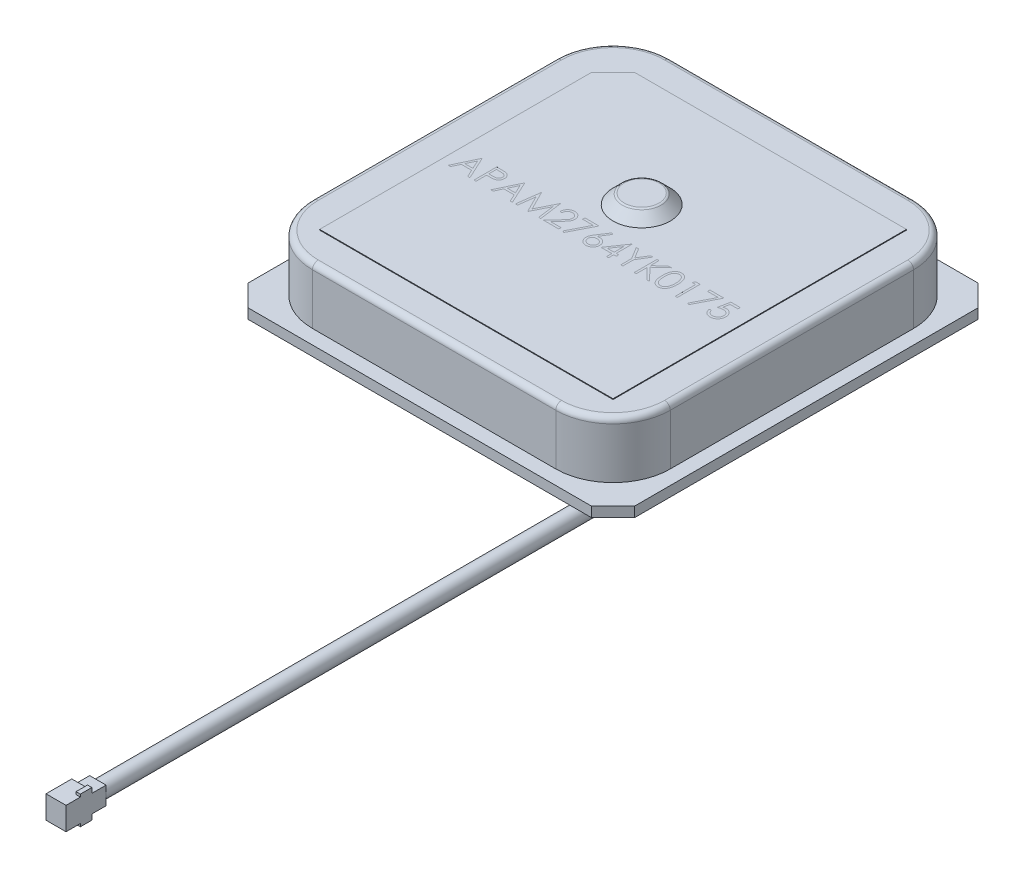
from build123d import *

# Parameters (mm, degrees)
SKETCH1_W                 = 27
SKETCH1_H                 = 27
BOSS_EXTRUDE1_DEPTH       = 0.7
CHAMFER2_SIZE             = 1.5
SKETCH2_W                 = 25
SKETCH2_H                 = 25
BOSS_EXTRUDE3_DEPTH       = 3.95
FILLET3_R                 = 4
FILLET4_R                 = 0.4
SKETCH5_W                 = 20.5
SKETCH5_H                 = 20.5
BOSS_EXTRUDE6_DEPTH       = 0.05
CHAMFER1_SIZE             = 1.5
SKETCH4_R                 = 2
BOSS_EXTRUDE5_DEPTH       = 0.7
BOSS_EXTRUDE5_TAPER       = 45
FILLET1_R                 = 0.2
SKETCH3_W                 = 15
SKETCH3_H                 = 11
BOSS_EXTRUDE4_DEPTH       = 1.3
SKETCH6_R                 = 0.565
BOSS_EXTRUDE10_DEPTH      = 48
SKETCH7_W                 = 1.8
SKETCH7_H                 = 1.6
BOSS_EXTRUDE11_DEPTH      = 1.4
SKETCH8_W                 = 1
SKETCH8_H                 = 1.25
BOSS_EXTRUDE12_DEPTH      = 1.15
SKETCH9_W                 = 0.3
SKETCH9_H                 = 0.8
BOSS_EXTRUDE13_DEPTH      = 0.18
BOSS_EXTRUDE13_DEPTH_BACK = 1.8
CUT_EXTRUDE1_DEPTH        = 0.0001


with BuildPart() as part:
    # Sketch1 → Boss-Extrude1 (new body)
    with BuildSketch(Plane(origin=(0, 0, 0), x_dir=(1, 0, 0), z_dir=(0, 1, 0))):
        Rectangle(SKETCH1_W, SKETCH1_H)
    extrude(amount=BOSS_EXTRUDE1_DEPTH)

    # Chamfer2
    chamfer2_edges = [part.edges().sort_by_distance(p)[0] for p in [
        (-13.5, 0.35, -13.5),
        (13.5, 0.35, -13.5),
        (13.5, 0.35, 13.5),
        (-13.5, 0.35, 13.5),
    ]]
    chamfer(chamfer2_edges, length=CHAMFER2_SIZE)

    # Sketch3 → Boss-Extrude4 (add)
    with BuildSketch(Plane(origin=(0, 0, 0), x_dir=(-1, 0, 0), z_dir=(0, -1, 0))):
        with Locations((-4, 4)):
            Rectangle(SKETCH3_W, SKETCH3_H)
    extrude(amount=BOSS_EXTRUDE4_DEPTH)


with BuildPart() as body_2:
    # Sketch2 → Boss-Extrude3 (new body)
    with BuildSketch(Plane(origin=(0, 0.7, 0), x_dir=(1, 0, 0), z_dir=(0, 1, 0))):
        Rectangle(SKETCH2_W, SKETCH2_H)
    extrude(amount=BOSS_EXTRUDE3_DEPTH)

    # Fillet3
    fillet3_edges = [body_2.edges().sort_by_distance(p)[0] for p in [
        (-12.5, 2.675, -12.5),
        (12.5, 2.675, -12.5),
        (12.5, 2.675, 12.5),
        (-12.5, 2.675, 12.5),
    ]]
    fillet(fillet3_edges, radius=FILLET3_R)

    # Fillet4
    fillet4_edges = [body_2.edges().sort_by_distance(p)[0] for p in [
        (0, 4.65, -12.5),
        (12.5, 4.65, 0),
        (-12.5, 4.65, 0),
        (0, 4.65, 12.5),
        (-11.328427125, 4.65, -11.328427125),
        (-11.328427125, 4.65, 11.328427125),
        (11.328427125, 4.65, 11.328427125),
        (11.328427125, 4.65, -11.328427125),
    ]]
    fillet(fillet4_edges, radius=FILLET4_R)

    # Sketch5 → Boss-Extrude6 (add)
    with BuildSketch(Plane(origin=(0, 4.65, 0), x_dir=(1, 0, 0), z_dir=(0, 1, 0))):
        Rectangle(SKETCH5_W, SKETCH5_H)
    extrude(amount=BOSS_EXTRUDE6_DEPTH)

    # Chamfer1
    chamfer1_edges = [body_2.edges().sort_by_distance(p)[0] for p in [
        (-10.25, 4.675, -10.25),
    ]]
    chamfer(chamfer1_edges, length=CHAMFER1_SIZE)

    # Sketch4 → Boss-Extrude5 (add)
    with BuildSketch(Plane(origin=(0, 4.7, 0), x_dir=(1, 0, 0), z_dir=(0, 1, 0))):
        with Locations((-0.5, 2.5)):
            Circle(SKETCH4_R)
    extrude(amount=BOSS_EXTRUDE5_DEPTH, taper=BOSS_EXTRUDE5_TAPER)

    # Fillet1
    fillet1_edges = [body_2.edges().sort_by_distance(p)[0] for p in [
        (-1.8, 5.4, -2.5),
    ]]
    fillet(fillet1_edges, radius=FILLET1_R)

    # Sketch10 → Cut-Extrude1 (cut)
    with BuildSketch(Plane(origin=(0, 4.7, 0), x_dir=(1, 0, 0), z_dir=(0, 1, 0))):
        Polygon((-8.856166827, -0.288785041), (-8.123474519, -1.876285041), (-8.278344812, -1.876285041), (-8.513035317, -1.367470939), (-9.232689263, -1.367470939), (-9.474057953, -1.876285041), (-9.629564263, -1.876285041), (-8.876519391, -0.288785041), align=None)
        Polygon((-8.867933153, -0.598207617), (-9.155413121, -1.204650426), (-8.588085397, -1.204650426), align=None, mode=Mode.SUBTRACT)
        with BuildLine():
            Line((-7.838538622, -0.288785041), (-7.527207993, -0.288785041))
            add(Edge.make_bspline(
                [(-7.527207993, -0.288785041), (-7.505794475, -0.28880858), (-7.464765223, -0.288853681), (-7.40593018, -0.290221083), (-7.352495052, -0.292047476), (-7.304575057, -0.294579263), (-7.262022756, -0.297571288), (-7.225030695, -0.301767749), (-7.19330811, -0.306149383), (-7.174300542, -0.310604092), (-7.165631971, -0.312635702)],
                knots=[0, 0, 0, 0, 6.4239e-05, 0.000123084, 0.000176543, 0.00022463, 0.000267045, 0.000304481, 0.000336323, 0.000363021, 0.000363021, 0.000363021, 0.000363021], degree=3))
            add(Edge.make_bspline(
                [(-7.165631971, -0.312635702), (-7.154658476, -0.315639229), (-7.132970061, -0.32157551), (-7.101718516, -0.333465306), (-7.071985165, -0.347563288), (-7.043667994, -0.363630575), (-7.017114978, -0.382356527), (-6.991929952, -0.402982061), (-6.968335175, -0.425983379), (-6.94646333, -0.451102501), (-6.926377011, -0.477917739), (-6.909082476, -0.506829393), (-6.894601198, -0.537350806), (-6.882180928, -0.569460747), (-6.873241737, -0.603428858), (-6.866507607, -0.639019117), (-6.862233319, -0.676227708), (-6.861823943, -0.701654862), (-6.861615545, -0.714598843)],
                knots=[0, 0, 0, 0, 3.4116e-05, 6.7428e-05, 0.000100146, 0.000132766, 0.000164967, 0.0001975, 0.000230334, 0.00026369, 0.000297336, 0.000330713, 0.000364566, 0.000398585, 0.00043384, 0.000469765, 0.000507201, 0.000546019, 0.000546019, 0.000546019, 0.000546019], degree=3))
            add(Edge.make_bspline(
                [(-6.861615545, -0.714598843), (-6.861806691, -0.72765162), (-6.862180682, -0.753190261), (-6.866669354, -0.790552204), (-6.872715548, -0.826256617), (-6.882012425, -0.860224332), (-6.894188856, -0.892253628), (-6.908472751, -0.922833972), (-6.925700995, -0.951445109), (-6.945497043, -0.978190909), (-6.967518659, -1.003096476), (-6.99167267, -1.025981329), (-7.017861564, -1.046711512), (-7.046002109, -1.065333496), (-7.076368648, -1.081415451), (-7.108500625, -1.095819658), (-7.14267733, -1.107916889), (-7.166327685, -1.114280524), (-7.178352324, -1.117516011)],
                knots=[0, 0, 0, 0, 3.9136e-05, 7.6572e-05, 0.000112752, 0.0001477, 0.000182017, 0.000215446, 0.000248823, 0.000282024, 0.000315141, 0.000348434, 0.000381709, 0.000415226, 0.000449515, 0.000484677, 0.000520786, 0.000558134, 0.000558134, 0.000558134, 0.000558134], degree=3))
            add(Edge.make_bspline(
                [(-7.178352324, -1.117516011), (-7.188297936, -1.119631006), (-7.210094323, -1.12426614), (-7.245991201, -1.12944069), (-7.287785715, -1.133857388), (-7.335420821, -1.137168975), (-7.38885376, -1.140003964), (-7.448113437, -1.142257349), (-7.51331618, -1.143495533), (-7.558796351, -1.143559392), (-7.582541527, -1.143592733)],
                knots=[0, 0, 0, 0, 3.0497e-05, 6.6837e-05, 0.000108733, 0.000156563, 0.000210065, 0.000269256, 0.00033446, 0.000405695, 0.000405695, 0.000405695, 0.000405695], degree=3))
            Line((-7.582541527, -1.143592733), (-7.696070673, -1.143592733))
            Line((-7.696070673, -1.143592733), (-7.696070673, -1.876285041))
            Line((-7.696070673, -1.876285041), (-7.838538622, -1.876285041))
            Line((-7.838538622, -1.876285041), (-7.838538622, -0.288785041))
        make_face()
        with BuildLine():
            Line((-7.696070673, -0.451605554), (-7.696070673, -0.980772221))
            Line((-7.696070673, -0.980772221), (-7.41813097, -0.984270318))
            add(Edge.make_bspline(
                [(-7.41813097, -0.984270318), (-7.404560146, -0.984277331), (-7.378361951, -0.984290871), (-7.340517664, -0.982483288), (-7.305407023, -0.980396618), (-7.273137877, -0.977341395), (-7.243695678, -0.973022825), (-7.217031334, -0.968663215), (-7.193351602, -0.96235614), (-7.16563875, -0.953863891), (-7.134758089, -0.939380169), (-7.101163165, -0.918357183), (-7.072692221, -0.891559862), (-7.048054993, -0.861430095), (-7.028503399, -0.827911562), (-7.014190502, -0.792048151), (-7.005780763, -0.754207662), (-7.004653096, -0.728314113), (-7.004083494, -0.715234861)],
                knots=[0, 0, 0, 0, 4.0706e-05, 7.8583e-05, 0.000113635, 0.000146227, 0.000175774, 0.00020291, 0.000227206, 0.000249231, 0.000289788, 0.00032913, 0.000367614, 0.000406503, 0.000445554, 0.000483525, 0.000521951, 0.00056117, 0.00056117, 0.00056117, 0.00056117], degree=3))
            add(Edge.make_bspline(
                [(-7.004083494, -0.715234861), (-7.004656194, -0.702472035), (-7.005794652, -0.677101117), (-7.014256418, -0.639917894), (-7.028475571, -0.604432413), (-7.048186241, -0.571333907), (-7.07210811, -0.541312556), (-7.099911741, -0.515233502), (-7.131531685, -0.494268659), (-7.160944989, -0.480737134), (-7.187071242, -0.472475206), (-7.209764309, -0.46669451), (-7.235386865, -0.462079146), (-7.263947251, -0.458341943), (-7.2952241, -0.455142695), (-7.329486122, -0.452971912), (-7.366603524, -0.451701252), (-7.392371176, -0.451638225), (-7.405728626, -0.451605554)],
                knots=[0, 0, 0, 0, 3.8268e-05, 7.6073e-05, 0.000113748, 0.000152526, 0.000191214, 0.000228567, 0.000266404, 0.00030454, 0.000325257, 0.00034855, 0.000374747, 0.000403306, 0.000434949, 0.000469048, 0.000506277, 0.000546348, 0.000546348, 0.000546348, 0.000546348], degree=3))
            Line((-7.405728626, -0.451605554), (-7.696070673, -0.451605554))
        make_face(mode=Mode.SUBTRACT)
        Polygon((-5.884692468, -0.288785041), (-5.15200016, -1.876285041), (-5.306870453, -1.876285041), (-5.541560958, -1.367470939), (-6.261214904, -1.367470939), (-6.502583594, -1.876285041), (-6.658089904, -1.876285041), (-5.905045032, -0.288785041), align=None)
        Polygon((-5.896458794, -0.598207617), (-6.183938762, -1.204650426), (-5.616611038, -1.204650426), align=None, mode=Mode.SUBTRACT)
        Polygon((-4.948474519, -1.876285041), (-4.738906711, -0.288785041), (-4.718554147, -0.288785041), (-4.063137981, -1.591349144), (-3.409311859, -0.288785041), (-3.388641286, -0.288785041), (-3.177801442, -1.876285041), (-3.320905409, -1.876285041), (-3.472913622, -0.733997381), (-4.045965505, -1.876285041), (-4.078084395, -1.876285041), (-4.65336234, -0.73145331), (-4.805052544, -1.876285041), align=None)
        with BuildLine():
            Line((-2.791102725, -0.77724658), (-2.933570673, -0.77724658))
            add(Edge.make_bspline(
                [(-2.933570673, -0.77724658), (-2.932642143, -0.758345855), (-2.930818535, -0.721225336), (-2.922278561, -0.667103422), (-2.910058948, -0.615371424), (-2.892781753, -0.566444713), (-2.871324977, -0.519890682), (-2.845593858, -0.475894247), (-2.815116647, -0.434623243), (-2.78055145, -0.396460268), (-2.74300996, -0.361450191), (-2.702503337, -0.331217277), (-2.659937914, -0.305673191), (-2.61544283, -0.284318485), (-2.568516074, -0.26828934), (-2.519583492, -0.256395954), (-2.468430098, -0.249240254), (-2.43357766, -0.248471094), (-2.415852324, -0.248079913)],
                knots=[0, 0, 0, 0, 5.6734e-05, 0.000111424, 0.000164104, 0.000216001, 0.000266797, 0.000317683, 0.00036863, 0.00042042, 0.000471954, 0.00052239, 0.000571747, 0.00062068, 0.000670161, 0.000720219, 0.000771579, 0.000824733, 0.000824733, 0.000824733, 0.000824733], degree=3))
            add(Edge.make_bspline(
                [(-2.415852324, -0.248079913), (-2.398445126, -0.248487427), (-2.364240604, -0.249288178), (-2.314319619, -0.256164788), (-2.266795632, -0.266935109), (-2.221761538, -0.28204603), (-2.179576644, -0.302358967), (-2.139924049, -0.326759994), (-2.102331681, -0.354981131), (-2.068492176, -0.388206968), (-2.037418868, -0.423677335), (-2.010611774, -0.461545063), (-1.987655089, -0.500656203), (-1.968519963, -0.541308995), (-1.954433786, -0.583886211), (-1.943739384, -0.627767978), (-1.93769445, -0.673408518), (-1.936766704, -0.704299705), (-1.936295032, -0.720004993)],
                knots=[0, 0, 0, 0, 5.2201e-05, 0.000102573, 0.000150864, 0.00019823, 0.000244744, 0.000290994, 0.000337742, 0.000385422, 0.000432989, 0.000479051, 0.000524375, 0.000568907, 0.000613558, 0.00065868, 0.00070424, 0.000751358, 0.000751358, 0.000751358, 0.000751358], degree=3))
            add(Edge.make_bspline(
                [(-1.936295032, -0.720004993), (-1.937063048, -0.742115618), (-1.938585602, -0.785948858), (-1.951609622, -0.850362742), (-1.971950718, -0.912771186), (-1.996442377, -0.962998462), (-2.021149521, -1.003472225), (-2.043414212, -1.036795531), (-2.069478608, -1.072675511), (-2.09972207, -1.110992017), (-2.13351898, -1.152045178), (-2.171175461, -1.195810192), (-2.21296004, -1.241834888), (-2.242287289, -1.273269929), (-2.257483934, -1.289558779)],
                knots=[0, 0, 0, 0, 6.6275e-05, 0.000131387, 0.000196351, 0.000262772, 0.00029844, 0.000338571, 0.000382971, 0.000431446, 0.00048499, 0.000542489, 0.000604632, 0.000671463, 0.000671463, 0.000671463, 0.000671463], degree=3))
            Line((-2.257483934, -1.289558779), (-2.654676943, -1.713464528))
            Line((-2.654676943, -1.713464528), (-1.915942468, -1.713464528))
            Line((-1.915942468, -1.713464528), (-1.915942468, -1.876285041))
            Line((-1.915942468, -1.876285041), (-2.994628366, -1.876285041))
            Line((-2.994628366, -1.876285041), (-2.378963301, -1.219278831))
            add(Edge.make_bspline(
                [(-2.378963301, -1.219278831), (-2.363973724, -1.203631385), (-2.335181814, -1.173575843), (-2.294459002, -1.129696001), (-2.257883461, -1.088988173), (-2.22521843, -1.051529274), (-2.197172518, -1.016771385), (-2.172284042, -0.985840216), (-2.152342506, -0.95737659), (-2.130700165, -0.924383526), (-2.109738824, -0.884100796), (-2.091726434, -0.834873016), (-2.08074327, -0.784196726), (-2.07942572, -0.749951159), (-2.078762981, -0.732725346)],
                knots=[0, 0, 0, 0, 6.5005e-05, 0.000124862, 0.000179583, 0.000229184, 0.000273934, 0.000313568, 0.000348244, 0.000378147, 0.000431912, 0.000484023, 0.000535041, 0.000586677, 0.000586677, 0.000586677, 0.000586677], degree=3))
            add(Edge.make_bspline(
                [(-2.078762981, -0.732725346), (-2.079051335, -0.721893426), (-2.079619627, -0.700545791), (-2.084635083, -0.669246751), (-2.092214491, -0.639054853), (-2.103075376, -0.609877229), (-2.11741129, -0.582007237), (-2.134861716, -0.555410951), (-2.15499578, -0.529698456), (-2.178287249, -0.505589639), (-2.203873902, -0.483509235), (-2.230904151, -0.463949382), (-2.259501877, -0.447603071), (-2.289546504, -0.434202985), (-2.320954271, -0.423691294), (-2.353785923, -0.416407581), (-2.387950744, -0.411834455), (-2.411279509, -0.411215705), (-2.423166527, -0.410900426)],
                knots=[0, 0, 0, 0, 3.2476e-05, 6.4004e-05, 9.4855e-05, 0.000125748, 0.00015718, 0.000188669, 0.000221051, 0.000255013, 0.000289057, 0.000322329, 0.000354949, 0.00038769, 0.000420876, 0.000454127, 0.000488444, 0.000524096, 0.000524096, 0.000524096, 0.000524096], degree=3))
            add(Edge.make_bspline(
                [(-2.423166527, -0.410900426), (-2.435581154, -0.411224744), (-2.459961433, -0.411861651), (-2.495756852, -0.416316931), (-2.529904329, -0.42400308), (-2.562489764, -0.434515357), (-2.59356829, -0.447876913), (-2.622988768, -0.464519241), (-2.650685149, -0.484378182), (-2.676709501, -0.50689372), (-2.700687092, -0.531961525), (-2.721754068, -0.559906044), (-2.740161817, -0.59021705), (-2.756222433, -0.622812757), (-2.769265193, -0.657988936), (-2.779231586, -0.695620716), (-2.787117763, -0.7355447), (-2.789752342, -0.763115078), (-2.791102725, -0.77724658)],
                knots=[0, 0, 0, 0, 3.7241e-05, 7.3135e-05, 0.000108008, 0.0001421, 0.000175714, 0.000209321, 0.000243294, 0.000277788, 0.000312429, 0.000347156, 0.000382552, 0.000418676, 0.000456008, 0.000494889, 0.000535366, 0.000577929, 0.000577929, 0.000577929, 0.000577929], degree=3))
        make_face()
        Polygon((-1.671711699, -0.288785041), (-0.694788622, -0.288785041), (-1.52924375, -1.916990169), (-1.652313161, -1.849254292), (-0.935839303, -0.451605554), (-1.671711699, -0.451605554), align=None)
        with BuildLine():
            Line((0.180371634, -0.248079913), (0.290084675, -0.334260301))
            Line((0.290084675, -0.334260301), (-0.12936895, -0.97568408))
            add(Edge.make_bspline(
                [(-0.12936895, -0.97568408), (-0.101442432, -0.971232793), (-0.0469686, -0.962550055), (0.008170218, -0.961117701), (0.035041606, -0.960419656)],
                knots=[0, 0, 0, 0, 8.4731e-05, 0.000165278, 0.000165278, 0.000165278, 0.000165278], degree=3))
            add(Edge.make_bspline(
                [(0.035041606, -0.960419656), (0.051176274, -0.960853321), (0.082936888, -0.961706978), (0.129567116, -0.968276439), (0.174374955, -0.978629257), (0.217174686, -0.993720602), (0.258119932, -1.012998456), (0.297445661, -1.036102872), (0.334412645, -1.064226877), (0.369496929, -1.095643482), (0.401349934, -1.130440114), (0.429551217, -1.167361435), (0.453239797, -1.206368977), (0.472459397, -1.247442984), (0.48738411, -1.290520141), (0.498264221, -1.335545333), (0.504695679, -1.382549608), (0.505569026, -1.414516494), (0.50601266, -1.430754693)],
                knots=[0, 0, 0, 0, 4.8389e-05, 9.5251e-05, 0.000140993, 0.000186151, 0.000231106, 0.000276592, 0.000322703, 0.000370214, 0.000417704, 0.000464007, 0.000509383, 0.000554338, 0.000599797, 0.000645921, 0.000693099, 0.000741806, 0.000741806, 0.000741806, 0.000741806], degree=3))
            add(Edge.make_bspline(
                [(0.50601266, -1.430754693), (0.50536718, -1.452970487), (0.504097029, -1.496685912), (0.491440664, -1.560356776), (0.471773968, -1.621014024), (0.443662732, -1.677689212), (0.408745723, -1.730304663), (0.366165529, -1.776925214), (0.317432233, -1.818504124), (0.262329292, -1.853273376), (0.203028019, -1.881668331), (0.140729077, -1.90206328), (0.076037479, -1.914619711), (0.032129674, -1.916193877), (0.00991891, -1.916990169)],
                knots=[0, 0, 0, 0, 6.6573e-05, 0.000131001, 0.000193953, 0.000257384, 0.000320182, 0.000382775, 0.000446173, 0.000511807, 0.000577667, 0.000642933, 0.000707985, 0.000774577, 0.000774577, 0.000774577, 0.000774577], degree=3))
            add(Edge.make_bspline(
                [(0.00991891, -1.916990169), (-0.011442808, -1.916297019), (-0.053756631, -1.914924009), (-0.116001505, -1.90269303), (-0.175810802, -1.882868737), (-0.232765486, -1.855557261), (-0.285525192, -1.821059578), (-0.332726392, -1.779529544), (-0.374133732, -1.731854894), (-0.40859365, -1.678043022), (-0.435925289, -1.62021722), (-0.456422148, -1.559920724), (-0.468394729, -1.497373233), (-0.470067753, -1.454972859), (-0.470910417, -1.433616772)],
                knots=[0, 0, 0, 0, 6.4034e-05, 0.000126839, 0.00018949, 0.000252643, 0.000315795, 0.00037799, 0.000440665, 0.000504617, 0.000569054, 0.000632108, 0.000695226, 0.000759279, 0.000759279, 0.000759279, 0.000759279], degree=3))
            add(Edge.make_bspline(
                [(-0.470910417, -1.433616772), (-0.470374547, -1.417267979), (-0.469280404, -1.383886867), (-0.461640723, -1.333329969), (-0.449364905, -1.281599656), (-0.435617044, -1.237714719), (-0.421091142, -1.201763957), (-0.409002311, -1.172779159), (-0.393955535, -1.142951815), (-0.37791118, -1.111259131), (-0.359425028, -1.078517881), (-0.339324716, -1.044180859), (-0.317054517, -1.008794156), (-0.301442515, -0.984780182), (-0.293461499, -0.972503991)],
                knots=[0, 0, 0, 0, 4.9039e-05, 0.000100129, 0.000153045, 0.00020846, 0.000237868, 0.000269353, 0.000302633, 0.000338048, 0.000375916, 0.000415403, 0.000457404, 0.000501332, 0.000501332, 0.000501332, 0.000501332], degree=3))
            Line((-0.293461499, -0.972503991), (0.180371634, -0.248079913))
        make_face()
        with BuildLine():
            add(Edge.make_bspline(
                [(0.005148778, -1.123240169), (-0.006944455, -1.123593068), (-0.030566051, -1.124282381), (-0.065222271, -1.128285263), (-0.098021496, -1.135823196), (-0.129398267, -1.14542364), (-0.158765975, -1.158623956), (-0.186338056, -1.174658522), (-0.212221133, -1.193536699), (-0.236144101, -1.214991041), (-0.257833734, -1.238480613), (-0.276512319, -1.263640003), (-0.292624264, -1.289862874), (-0.305724232, -1.317368327), (-0.315925088, -1.346145846), (-0.323303902, -1.376063077), (-0.327410425, -1.407320637), (-0.328093608, -1.428517165), (-0.328442468, -1.439340931)],
                knots=[0, 0, 0, 0, 3.6288e-05, 7.0881e-05, 0.000104442, 0.000137129, 0.00016916, 0.000200795, 0.000232663, 0.000265093, 0.000297053, 0.000328408, 0.000358951, 0.000389248, 0.000419624, 0.000450399, 0.000481522, 0.000513997, 0.000513997, 0.000513997, 0.000513997], degree=3))
            add(Edge.make_bspline(
                [(-0.328442468, -1.439340931), (-0.328158368, -1.450067886), (-0.327601291, -1.471101848), (-0.322542918, -1.502098547), (-0.314816291, -1.531927631), (-0.303322611, -1.56043532), (-0.289612559, -1.58805615), (-0.271512644, -1.613789654), (-0.251457173, -1.639198758), (-0.227484139, -1.662331568), (-0.201756042, -1.683856537), (-0.174269068, -1.702670795), (-0.145621515, -1.718766309), (-0.11542662, -1.731380628), (-0.084112781, -1.741733073), (-0.051419102, -1.749018101), (-0.017322842, -1.753136768), (0.005773894, -1.753820841), (0.017551122, -1.754169656)],
                knots=[0, 0, 0, 0, 3.2158e-05, 6.3057e-05, 9.3989e-05, 0.000124402, 0.000155123, 0.000186258, 0.00021859, 0.000252096, 0.000285973, 0.000319139, 0.00035188, 0.000384367, 0.000417151, 0.000450712, 0.000484674, 0.000520009, 0.000520009, 0.000520009, 0.000520009], degree=3))
            add(Edge.make_bspline(
                [(0.017551122, -1.754169656), (0.02932833, -1.753820814), (0.052425028, -1.753136687), (0.086521562, -1.749018409), (0.119214228, -1.741731943), (0.150531751, -1.731384722), (0.180713043, -1.718751121), (0.209335542, -1.702770929), (0.23656257, -1.683740832), (0.262307556, -1.662368353), (0.286180807, -1.639067095), (0.306717287, -1.614016471), (0.324262896, -1.587848168), (0.338520546, -1.560544125), (0.349887631, -1.531910393), (0.35765344, -1.502103165), (0.362701367, -1.471100639), (0.36325988, -1.450067477), (0.363544711, -1.439340931)],
                knots=[0, 0, 0, 0, 3.5335e-05, 6.9296e-05, 0.000102858, 0.000135642, 0.000168129, 0.00020087, 0.000233774, 0.000267651, 0.000301157, 0.00033369, 0.000364648, 0.000395515, 0.000425927, 0.000456859, 0.000487758, 0.000519917, 0.000519917, 0.000519917, 0.000519917], degree=3))
            add(Edge.make_bspline(
                [(0.363544711, -1.439340931), (0.363295114, -1.428503045), (0.362805236, -1.4072318), (0.357264431, -1.376077059), (0.349579854, -1.34599384), (0.337976122, -1.317171214), (0.322900975, -1.289722918), (0.304538859, -1.263510299), (0.283296943, -1.238332392), (0.258759844, -1.214944975), (0.232048917, -1.193560407), (0.203648276, -1.174682966), (0.173935731, -1.15875128), (0.142941407, -1.145458416), (0.110310171, -1.135865618), (0.076568839, -1.128312183), (0.041285861, -1.124292625), (0.017347899, -1.123595456), (0.005148778, -1.123240169)],
                knots=[0, 0, 0, 0, 3.2476e-05, 6.374e-05, 9.4672e-05, 0.000125497, 0.000156664, 0.000188421, 0.000221363, 0.000255324, 0.00028994, 0.000323897, 0.000357476, 0.000390965, 0.000424867, 0.00045936, 0.000494584, 0.00053119, 0.00053119, 0.00053119, 0.00053119], degree=3))
        make_face(mode=Mode.SUBTRACT)
        Polygon((1.535407191, -0.248079913), (1.564345993, -0.248079913), (1.564345993, -1.347118374), (1.74751907, -1.347118374), (1.74751907, -1.509938887), (1.564345993, -1.509938887), (1.564345993, -1.876285041), (1.421878045, -1.876285041), (1.421878045, -1.509938887), (0.668833173, -1.509938887), align=None)
        Polygon((1.421878045, -1.347118374), (1.421878045, -0.657675265), (0.948680929, -1.347118374), align=None, mode=Mode.SUBTRACT)
        Polygon((1.910339583, -0.288785041), (2.073478105, -0.288785041), (2.490705669, -0.970913947), (2.907297215, -0.288785041), (3.070435737, -0.288785041), (2.561621634, -1.121650125), (2.561621634, -1.876285041), (2.419153686, -1.876285041), (2.419153686, -1.121650125), align=None)
        Polygon((3.355371634, -0.288785041), (3.497839583, -0.288785041), (3.497839583, -0.893319797), (4.159615925, -0.288785041), (4.362823558, -0.288785041), (3.582747937, -1.001124785), (4.42388125, -1.876285041), (4.234029988, -1.876285041), (3.497839583, -1.110201808), (3.497839583, -1.876285041), (3.355371634, -1.876285041), align=None)
        with BuildLine():
            add(Edge.make_bspline(
                [(4.515467788, -1.083171059), (4.515616568, -1.057726886), (4.515905575, -1.008301215), (4.51912068, -0.936281038), (4.524461639, -0.868716907), (4.53178109, -0.805605588), (4.540688317, -0.746930787), (4.552578912, -0.692849308), (4.566101148, -0.643110844), (4.58177315, -0.5975532), (4.599456897, -0.555562599), (4.618703865, -0.516362597), (4.640277897, -0.480012507), (4.662945997, -0.445932152), (4.687625758, -0.414679404), (4.713614852, -0.385812911), (4.741927632, -0.359999821), (4.771601639, -0.336483819), (4.802905536, -0.315869237), (4.834947031, -0.297711531), (4.867946668, -0.282199448), (4.901994544, -0.270002715), (4.936784632, -0.259928509), (4.972438552, -0.253039237), (5.009015171, -0.248704496), (5.033703714, -0.248290083), (5.046224499, -0.248079913)],
                knots=[0, 0, 0, 0, 7.6328e-05, 0.000148268, 0.00021622, 0.000279609, 0.000338845, 0.000394172, 0.000445631, 0.000493402, 0.000538583, 0.000582245, 0.000624295, 0.000665308, 0.000704942, 0.000743661, 0.000781696, 0.00081974, 0.000857137, 0.000894018, 0.000930155, 0.000966372, 0.001002409, 0.001038707, 0.001075195, 0.001112741, 0.001112741, 0.001112741, 0.001112741], degree=3))
            add(Edge.make_bspline(
                [(5.046224499, -0.248079913), (5.058849877, -0.248301172), (5.083957781, -0.248741186), (5.121078237, -0.25297026), (5.157341128, -0.25998752), (5.192591855, -0.269930248), (5.227119974, -0.282265429), (5.260655416, -0.297726372), (5.293406485, -0.315723572), (5.324852723, -0.336870831), (5.355339352, -0.360448506), (5.384117535, -0.387101574), (5.411189892, -0.416560911), (5.436896191, -0.448511328), (5.460507123, -0.483565634), (5.482992215, -0.521114141), (5.503118103, -0.561813498), (5.522501331, -0.604984638), (5.539232214, -0.651822084), (5.554320832, -0.702061814), (5.566512365, -0.756297249), (5.576667499, -0.814243832), (5.584534648, -0.876114369), (5.590264454, -0.941776233), (5.593291174, -1.011272625), (5.593861178, -1.058787792), (5.594153686, -1.083171059)],
                knots=[0, 0, 0, 0, 3.7864e-05, 7.53e-05, 0.00011191, 0.00014856, 0.000185076, 0.00022179, 0.000259226, 0.000297064, 0.000335358, 0.000374741, 0.000414574, 0.000455299, 0.000497637, 0.000541268, 0.000586494, 0.000633765, 0.000683159, 0.00073558, 0.000791046, 0.000849811, 0.000912015, 0.000978091, 0.00104749, 0.001120643, 0.001120643, 0.001120643, 0.001120643], degree=3))
            add(Edge.make_bspline(
                [(5.594153686, -1.083171059), (5.593858146, -1.107447974), (5.593282298, -1.154750554), (5.590298384, -1.223934246), (5.584420719, -1.289247644), (5.577068332, -1.35084739), (5.566885217, -1.408477095), (5.554364302, -1.462336185), (5.540462191, -1.512657246), (5.52330141, -1.559028035), (5.504518694, -1.602095424), (5.484082945, -1.642312309), (5.462189131, -1.680034163), (5.438336379, -1.714959048), (5.412912152, -1.747334368), (5.385372298, -1.776588647), (5.356493139, -1.803426773), (5.325916794, -1.827308047), (5.293980126, -1.848210797), (5.261341544, -1.866904222), (5.227421938, -1.881977623), (5.192989992, -1.894920303), (5.157553197, -1.904808365), (5.121155727, -1.911645435), (5.08398272, -1.916440523), (5.058854153, -1.91680632), (5.046224499, -1.916990169)],
                knots=[0, 0, 0, 0, 7.2835e-05, 0.000141916, 0.000207676, 0.000269524, 0.000327976, 0.000383132, 0.000435376, 0.000484471, 0.000531323, 0.000576265, 0.000619734, 0.000662073, 0.000703046, 0.000743095, 0.000782478, 0.000821219, 0.000859322, 0.000896913, 0.000933917, 0.000970542, 0.001007192, 0.001044114, 0.001081586, 0.00111945, 0.00111945, 0.00111945, 0.00111945], degree=3))
            add(Edge.make_bspline(
                [(5.046224499, -1.916990169), (5.033704062, -1.916778644), (5.009016203, -1.916361557), (4.972434567, -1.9120464), (4.936927887, -1.905108797), (4.902320952, -1.895394837), (4.868436212, -1.883504536), (4.835735396, -1.868013401), (4.803854911, -1.850172591), (4.772879812, -1.829854668), (4.743392154, -1.806576619), (4.715226, -1.780829959), (4.689088938, -1.751972198), (4.664762045, -1.720458997), (4.641641655, -1.686580276), (4.620373975, -1.649873479), (4.600702195, -1.610484152), (4.58272104, -1.568157814), (4.56677861, -1.522276829), (4.552696257, -1.472316308), (4.541577336, -1.417835288), (4.532060067, -1.359271339), (4.52438365, -1.296372806), (4.519142938, -1.229105543), (4.515903842, -1.157511466), (4.515615792, -1.108403389), (4.515467788, -1.083171059)],
                knots=[0, 0, 0, 0, 3.7547e-05, 7.4035e-05, 0.000110332, 0.000145978, 0.000181787, 0.000217924, 0.000254372, 0.000291328, 0.000328926, 0.000366961, 0.00040568, 0.000445564, 0.000486314, 0.000528639, 0.000572726, 0.000618325, 0.0006665, 0.000718351, 0.000773922, 0.000833209, 0.00089632, 0.000963954, 0.001035576, 0.001111269, 0.001111269, 0.001111269, 0.001111269], degree=3))
        make_face()
        with BuildLine():
            add(Edge.make_bspline(
                [(4.657935737, -1.082535041), (4.657989915, -1.103738915), (4.658095063, -1.144891471), (4.660841983, -1.204691807), (4.664584052, -1.260467635), (4.669410641, -1.312289775), (4.676578407, -1.359982816), (4.6846097, -1.40387478), (4.694383297, -1.443733384), (4.705947109, -1.479832141), (4.719118414, -1.512783682), (4.733499288, -1.543445662), (4.748948258, -1.57218029), (4.766238016, -1.598729463), (4.785068062, -1.623179759), (4.805013076, -1.645963936), (4.826817427, -1.666282567), (4.856981625, -1.690651533), (4.896803597, -1.715833426), (4.946977875, -1.737761831), (4.998534637, -1.751542445), (5.033528239, -1.753294935), (5.050994631, -1.754169656)],
                knots=[0, 0, 0, 0, 6.3605e-05, 0.000123445, 0.000179544, 0.000231312, 0.000279524, 0.000324181, 0.000365137, 0.000402548, 0.000437803, 0.000471519, 0.000504107, 0.000535596, 0.000566445, 0.00059663, 0.000626326, 0.000655728, 0.000712899, 0.000767017, 0.000819542, 0.000871885, 0.000871885, 0.000871885, 0.000871885], degree=3))
            add(Edge.make_bspline(
                [(5.050994631, -1.754169656), (5.068574004, -1.753444949), (5.103696454, -1.75199703), (5.155010711, -1.738027602), (5.204826583, -1.716950347), (5.243866356, -1.692027728), (5.273567367, -1.668293093), (5.294847573, -1.648057163), (5.314379288, -1.625398609), (5.332904086, -1.600951429), (5.349894453, -1.574248552), (5.365344519, -1.545418384), (5.379443037, -1.514380864), (5.387475355, -1.492713875), (5.391582071, -1.481636103)],
                knots=[0, 0, 0, 0, 5.2634e-05, 0.000105159, 0.000158441, 0.000214466, 0.00024342, 0.000272436, 0.000302411, 0.000333067, 0.000364384, 0.000397252, 0.000431124, 0.000466559, 0.000466559, 0.000466559, 0.000466559], degree=3))
            add(Edge.make_bspline(
                [(5.391582071, -1.481636103), (5.396368052, -1.467471185), (5.406085644, -1.438710328), (5.418609556, -1.394095386), (5.428472648, -1.347285561), (5.437346032, -1.298560597), (5.443402596, -1.247561161), (5.448277497, -1.194445051), (5.451148916, -1.139172219), (5.451504857, -1.101618777), (5.451685737, -1.082535041)],
                knots=[0, 0, 0, 0, 4.4852e-05, 9.1068e-05, 0.00013891, 0.000188317, 0.000239595, 0.000292916, 0.000348323, 0.000405573, 0.000405573, 0.000405573, 0.000405573], degree=3))
            add(Edge.make_bspline(
                [(5.451685737, -1.082535041), (5.451436187, -1.063454392), (5.450948014, -1.026128564), (5.449082026, -0.97146496), (5.444263476, -0.919545655), (5.438911733, -0.870146976), (5.431020851, -0.823542374), (5.422512846, -0.7793417), (5.411082296, -0.738092542), (5.398872255, -0.699149089), (5.38489754, -0.662953792), (5.369514332, -0.629337897), (5.353085177, -0.598139111), (5.335240661, -0.569443034), (5.316192619, -0.54312113), (5.295438302, -0.519701153), (5.273800961, -0.498457243), (5.243494595, -0.474208149), (5.203818756, -0.449483201), (5.15444948, -0.426729446), (5.103073152, -0.413662828), (5.068341622, -0.411820562), (5.050994631, -0.410900426)],
                knots=[0, 0, 0, 0, 5.725e-05, 0.000111992, 0.000164019, 0.000213641, 0.000261007, 0.000305787, 0.0003486, 0.000389331, 0.000428191, 0.000464905, 0.000500186, 0.000533895, 0.000566207, 0.000597529, 0.000627664, 0.000657066, 0.000713798, 0.000767462, 0.000819601, 0.000871627, 0.000871627, 0.000871627, 0.000871627], degree=3))
            add(Edge.make_bspline(
                [(5.050994631, -0.410900426), (5.033436613, -0.411821832), (4.998288589, -0.413666323), (4.946378267, -0.426680763), (4.896619507, -0.449365215), (4.857048587, -0.474290041), (4.826721083, -0.498029204), (4.805365719, -0.518615203), (4.785342277, -0.541133325), (4.76689657, -0.56580848), (4.749620359, -0.5923267), (4.733753971, -0.620896604), (4.719458611, -0.651662972), (4.706266696, -0.684599713), (4.69466761, -0.720695355), (4.685099991, -0.760504863), (4.676261221, -0.804257221), (4.670004081, -0.85220857), (4.664441592, -0.904043689), (4.660866838, -0.959958758), (4.658085874, -1.019859388), (4.657986785, -1.061224721), (4.657935737, -1.082535041)],
                knots=[0, 0, 0, 0, 5.266e-05, 0.000105416, 0.000159371, 0.000216103, 0.000245306, 0.000274771, 0.000304957, 0.000335613, 0.000367102, 0.000399843, 0.00043356, 0.000468814, 0.000506226, 0.000547181, 0.000591587, 0.000640068, 0.000692185, 0.000747967, 0.000808124, 0.000872047, 0.000872047, 0.000872047, 0.000872047], degree=3))
        make_face(mode=Mode.SUBTRACT)
        Polygon((6.074028986, -0.288785041), (6.367551122, -0.288785041), (6.367551122, -1.876285041), (6.225083173, -1.876285041), (6.225083173, -0.451605554), (5.980852404, -0.451605554), align=None)
        Polygon((7.059538301, -0.288785041), (8.036461378, -0.288785041), (7.20200625, -1.916990169), (7.078936839, -1.849254292), (7.795410697, -0.451605554), (7.059538301, -0.451605554), align=None)
        with BuildLine():
            Line((9.176204968, -0.288785041), (9.176204968, -0.451605554))
            Line((9.176204968, -0.451605554), (8.636226001, -0.451605554))
            Line((8.636226001, -0.451605554), (8.55068163, -0.869151127))
            add(Edge.make_bspline(
                [(8.55068163, -0.869151127), (8.567489116, -0.864510968), (8.600050962, -0.855521394), (8.648111327, -0.845540205), (8.693737077, -0.839523378), (8.72334412, -0.83870182), (8.737670813, -0.838304272)],
                knots=[0, 0, 0, 0, 5.2298e-05, 0.000101319, 0.000147153, 0.000190126, 0.000190126, 0.000190126, 0.000190126], degree=3))
            add(Edge.make_bspline(
                [(8.737670813, -0.838304272), (8.755398081, -0.838687964), (8.790254318, -0.839442399), (8.841253412, -0.846686774), (8.889936546, -0.858089521), (8.936201906, -0.874019186), (8.980135085, -0.894388958), (9.021331872, -0.919834288), (9.060410639, -0.949558334), (9.096670316, -0.983732679), (9.12956527, -1.021343555), (9.158487701, -1.061783018), (9.183054304, -1.104658065), (9.202812218, -1.150378341), (9.218589398, -1.198438386), (9.229090482, -1.249343878), (9.23608306, -1.30261499), (9.236864286, -1.339038849), (9.23726266, -1.357612665)],
                knots=[0, 0, 0, 0, 5.3154e-05, 0.000104514, 0.000154189, 0.000202965, 0.000251051, 0.000299156, 0.00034794, 0.00039811, 0.000448368, 0.000497609, 0.000547033, 0.000596307, 0.000646791, 0.000698498, 0.000752023, 0.000807719, 0.000807719, 0.000807719, 0.000807719], degree=3))
            add(Edge.make_bspline(
                [(9.23726266, -1.357612665), (9.236961001, -1.37054953), (9.236361759, -1.396248427), (9.2333144, -1.434413833), (9.227447129, -1.471771261), (9.219569625, -1.508325667), (9.209345029, -1.544007846), (9.196967493, -1.578919932), (9.181820009, -1.612844629), (9.165205064, -1.646102933), (9.14649684, -1.67794297), (9.125733017, -1.707719475), (9.103795812, -1.735879131), (9.080191327, -1.762119931), (9.054700161, -1.786269443), (9.027631033, -1.808470985), (8.999199943, -1.829100017), (8.968967029, -1.847319163), (8.937605975, -1.864084504), (8.904663891, -1.877838394), (8.870890644, -1.890134955), (8.835800147, -1.899936419), (8.799471882, -1.907616542), (8.761845966, -1.912832886), (8.723119734, -1.916632199), (8.696869281, -1.916870032), (8.683609315, -1.916990169)],
                knots=[0, 0, 0, 0, 3.8818e-05, 7.7111e-05, 0.000114756, 0.000152181, 0.000189223, 0.000226038, 0.000263203, 0.000300607, 0.00033753, 0.000373874, 0.000409435, 0.00044456, 0.000479651, 0.000514668, 0.000549529, 0.000584925, 0.000620487, 0.000656105, 0.000691915, 0.000728258, 0.000765306, 0.000803218, 0.000842173, 0.000881935, 0.000881935, 0.000881935, 0.000881935], degree=3))
            add(Edge.make_bspline(
                [(8.683609315, -1.916990169), (8.667791383, -1.916676825), (8.63667147, -1.916060357), (8.591078213, -1.909611258), (8.547211231, -1.900374768), (8.50542365, -1.886479031), (8.465340969, -1.869067651), (8.427502808, -1.847062102), (8.390942331, -1.822125151), (8.3571458, -1.792697277), (8.325778563, -1.760531949), (8.297699539, -1.725626162), (8.272692524, -1.688556022), (8.251157975, -1.649141502), (8.232789229, -1.607486169), (8.218358859, -1.56343395), (8.206711891, -1.51721502), (8.201784554, -1.485395392), (8.199281891, -1.469233759)],
                knots=[0, 0, 0, 0, 4.7422e-05, 9.3297e-05, 0.000137896, 0.000181742, 0.000225171, 0.000268757, 0.000312864, 0.000357739, 0.000402942, 0.000447492, 0.000491945, 0.000536918, 0.000582059, 0.000628318, 0.000675829, 0.000724868, 0.000724868, 0.000724868, 0.000724868], degree=3))
            Line((8.199281891, -1.469233759), (8.34174984, -1.469233759))
            add(Edge.make_bspline(
                [(8.34174984, -1.469233759), (8.345255292, -1.484372364), (8.351992967, -1.513469604), (8.366782003, -1.554350605), (8.384864025, -1.59078111), (8.406365284, -1.623243028), (8.432014762, -1.651549967), (8.461283467, -1.676776277), (8.494098327, -1.699534282), (8.530562399, -1.718503894), (8.569031189, -1.734682222), (8.609293459, -1.745455312), (8.65025293, -1.75303036), (8.677956334, -1.753788623), (8.691877544, -1.754169656)],
                knots=[0, 0, 0, 0, 4.6586e-05, 8.9541e-05, 0.000130073, 0.000168351, 0.000205959, 0.000244281, 0.000284064, 0.000325461, 0.00036739, 0.000408976, 0.000450278, 0.000491997, 0.000491997, 0.000491997, 0.000491997], degree=3))
            add(Edge.make_bspline(
                [(8.691877544, -1.754169656), (8.705465838, -1.753797375), (8.732221301, -1.75306435), (8.771596466, -1.747422369), (8.809611591, -1.738733042), (8.845891571, -1.725729215), (8.881071269, -1.709924647), (8.914260801, -1.689643166), (8.94642032, -1.666302372), (8.976550223, -1.639561329), (9.004145259, -1.610092932), (9.0285275, -1.578579971), (9.048837028, -1.544962687), (9.065952142, -1.509823078), (9.07894846, -1.472776019), (9.088219905, -1.433995128), (9.093664149, -1.39338462), (9.094413077, -1.365685325), (9.094794711, -1.351570498)],
                knots=[0, 0, 0, 0, 4.075e-05, 8.0237e-05, 0.000119113, 0.000157533, 0.000195669, 0.000234609, 0.000273982, 0.000314758, 0.000355256, 0.000394946, 0.000434051, 0.000472881, 0.000512006, 0.000551575, 0.000592322, 0.00063466, 0.00063466, 0.00063466, 0.00063466], degree=3))
            add(Edge.make_bspline(
                [(9.094794711, -1.351570498), (9.094496044, -1.338836139), (9.093911445, -1.313910444), (9.089135079, -1.277443661), (9.080827024, -1.242939102), (9.069295478, -1.210230146), (9.054654416, -1.179285942), (9.036762695, -1.150074554), (9.015284547, -1.122980994), (8.990750012, -1.097992586), (8.963872258, -1.074930803), (8.934188846, -1.055271164), (8.90232095, -1.038732173), (8.868652525, -1.024459188), (8.832382732, -1.014208135), (8.794229831, -1.006511987), (8.753781824, -1.002060019), (8.726127262, -1.001442306), (8.711912099, -1.001124785)],
                knots=[0, 0, 0, 0, 3.8194e-05, 7.476e-05, 0.000110086, 0.000144484, 0.000178623, 0.000212603, 0.000247021, 0.000282103, 0.000317528, 0.000353073, 0.000388634, 0.000425132, 0.000462568, 0.000501485, 0.0005418, 0.000584443, 0.000584443, 0.000584443, 0.000584443], degree=3))
            add(Edge.make_bspline(
                [(8.711912099, -1.001124785), (8.699607192, -1.001388124), (8.674200681, -1.001931854), (8.635228542, -1.0059353), (8.594274796, -1.012393838), (8.551496436, -1.0212776), (8.506764991, -1.032903124), (8.460174859, -1.046834344), (8.411628081, -1.063490393), (8.378917542, -1.076068933), (8.362102404, -1.082535041)],
                knots=[0, 0, 0, 0, 3.6911e-05, 7.6212e-05, 0.000117411, 0.000161256, 0.000207225, 0.000256022, 0.000307109, 0.000361153, 0.000361153, 0.000361153, 0.000361153], degree=3))
            Line((8.362102404, -1.082535041), (8.524922917, -0.288785041))
            Line((8.524922917, -0.288785041), (9.176204968, -0.288785041))
        make_face()
    extrude(amount=-CUT_EXTRUDE1_DEPTH, mode=Mode.SUBTRACT)


with BuildPart() as body_3:
    # Sketch6 → Boss-Extrude10 (new body)
    with BuildSketch(Plane.XY.offset(1.5)):
        with Locations((10.7, -0.565)):
            Circle(SKETCH6_R)
    extrude(amount=BOSS_EXTRUDE10_DEPTH)

    # Sketch7 → Boss-Extrude11 (add)
    with BuildSketch(Plane(origin=(11.28, 0, 0), x_dir=(0, 0, -1), z_dir=(1, 0, 0))):
        with Locations((-48.6, -0.565)):
            Rectangle(SKETCH7_W, SKETCH7_H)
    extrude(amount=-BOSS_EXTRUDE11_DEPTH)

    # Sketch8 → Boss-Extrude12 (add)
    with BuildSketch(Plane(origin=(11.28, 0, 0), x_dir=(0, 0, -1), z_dir=(1, 0, 0))):
        with Locations((-47.2, -0.565)):
            Rectangle(SKETCH8_W, SKETCH8_H)
    extrude(amount=-BOSS_EXTRUDE12_DEPTH)

    # Sketch9 → Boss-Extrude13 (add, two sides)
    with BuildSketch(Plane(origin=(0, 0.235, 0), x_dir=(1, 0, 0), z_dir=(0, 1, 0))) as boss_extrude13_sk:
        with Locations((11.13, -48.1)):
            Rectangle(SKETCH9_W, SKETCH9_H)
    extrude(amount=BOSS_EXTRUDE13_DEPTH)
    extrude(boss_extrude13_sk.sketch, amount=-BOSS_EXTRUDE13_DEPTH_BACK)


solid = Compound([part.part, body_2.part, body_3.part])
